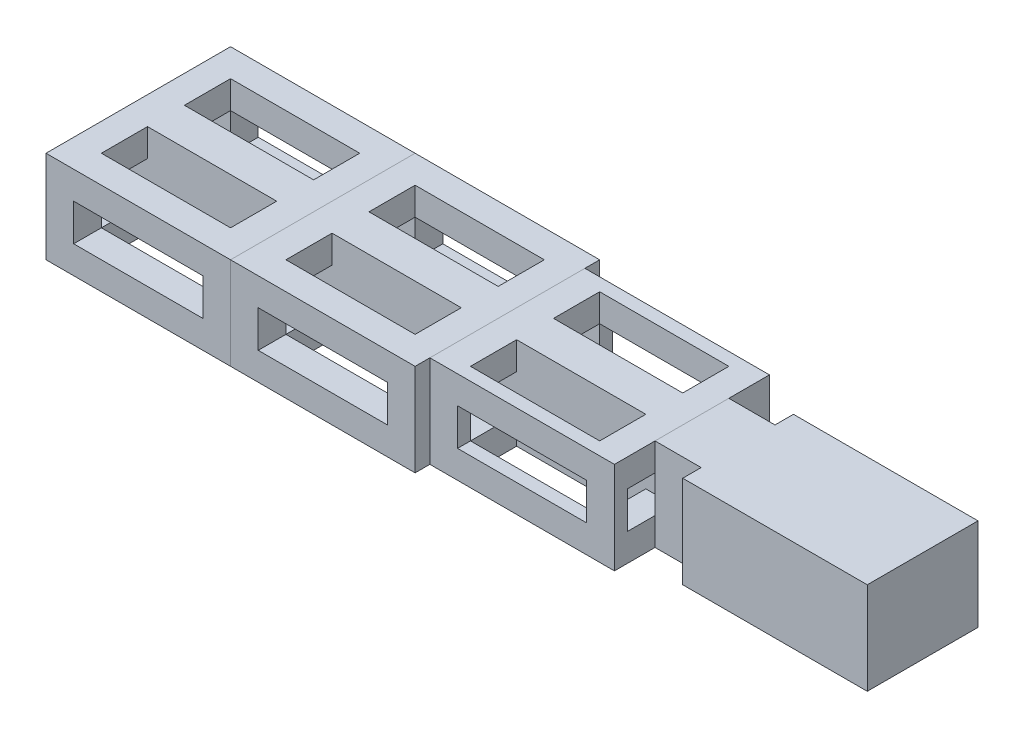
from build123d import *

# Parameters (mm, degrees)
SKETCH_1_W           = 20
SKETCH_1_H           = 20
EXTRUDE_1_DEPTH      = 10
SKETCH_1_3_W         = 20
SKETCH_1_3_H         = 20
EXTRUDE_2_DEPTH      = 10
SKETCH_1_4_W         = 20
SKETCH_1_4_H         = 20
EXTRUDE_3_DEPTH      = 10
SKETCH_2_W           = 14
SKETCH_2_H           = 4
CUT_EXTRUDE_1_DEPTH  = 61
SKETCH_3_W           = 14
SKETCH_3_H           = 4
CUT_EXTRUDE_2_DEPTH  = 21
SKETCH_4_W           = 14
SKETCH_4_H           = 14
CUT_EXTRUDE_3_DEPTH  = 11
SKETCH_5_W           = 20
SKETCH_5_H           = 10
EXTRUDE_4_DEPTH      = 10
EXTRUDE_4_DEPTH_BACK = 10
SKETCH_6_W           = 8
SKETCH_6_H           = 10
EXTRUDE_5_DEPTH      = 5
SKETCH_7_W           = 20
SKETCH_7_H           = 10
CUT_EXTRUDE_4_DEPTH  = 1.6
CUT_EXTRUDE_START    = -20
SKETCH_7_2_W         = 20
SKETCH_7_2_H         = 10
CUT_EXTRUDE_5_DEPTH  = 1.6
SKETCH_8_W           = 20
SKETCH_8_H           = 10
CUT_EXTRUDE_6_DEPTH  = 4
SKETCH_8_2_W         = 20
SKETCH_8_2_H         = 10
CUT_EXTRUDE_9_DEPTH  = 4
SKETCH_9_W           = 4
SKETCH_9_H           = 10
EXTRUDE_6_DEPTH      = 20
SKETCH_10_W          = 4
SKETCH_10_H          = 10
EXTRUDE_7_DEPTH      = 20
SKETCH_11_W          = 4
SKETCH_11_H          = 10
EXTRUDE_8_DEPTH      = 20


with BuildPart() as part:
    # Sketch 1 → Extrude 1 (new body)
    with BuildSketch(Plane(origin=(0, 0, 0), x_dir=(1, 0, 0), z_dir=(0, 1, 0))):
        with Locations((-20, 0)):
            Rectangle(SKETCH_1_W, SKETCH_1_H)
    extrude(amount=EXTRUDE_1_DEPTH)


with BuildPart() as body_2:
    # Sketch 1_3 → Extrude 2 (new body)
    with BuildSketch(Plane(origin=(0, 0, 0), x_dir=(1, 0, 0), z_dir=(0, 1, 0))):
        Rectangle(SKETCH_1_3_W, SKETCH_1_3_H)
    extrude(amount=EXTRUDE_2_DEPTH)


with BuildPart() as body_3:
    # Sketch 1_4 → Extrude 3 (new body)
    with BuildSketch(Plane(origin=(0, 0, 0), x_dir=(1, 0, 0), z_dir=(0, 1, 0))):
        with Locations((20, 0)):
            Rectangle(SKETCH_1_4_W, SKETCH_1_4_H)
    extrude(amount=EXTRUDE_3_DEPTH)


with BuildPart() as cut_extrude_1_tool:
    # Sketch 2 → Cut-Extrude 1 (new body, through all)
    with BuildSketch(Plane.ZY.offset(30)):
        with Locations((0, 5)):
            Rectangle(SKETCH_2_W, SKETCH_2_H)
    extrude(amount=-CUT_EXTRUDE_1_DEPTH)


with BuildPart() as part_1:
    add(part.part)

    # Cut-Extrude 1: cut by cut_extrude_1_tool
    add(cut_extrude_1_tool.part, mode=Mode.SUBTRACT)


with BuildPart() as body_2_1:
    add(body_2.part)

    # Cut-Extrude 1: cut by cut_extrude_1_tool
    add(cut_extrude_1_tool.part, mode=Mode.SUBTRACT)


with BuildPart() as body_3_1:
    add(body_3.part)

    # Cut-Extrude 1: cut by cut_extrude_1_tool
    add(cut_extrude_1_tool.part, mode=Mode.SUBTRACT)


with BuildPart() as cut_extrude_2_tool:
    # Sketch 3 → Cut-Extrude 2 (new body, through all)
    with BuildSketch(Plane(origin=(0, 0, -10), x_dir=(-1, 0, 0), z_dir=(0, 0, -1))):
        with Locations((-20, 5)):
            Rectangle(SKETCH_3_W, SKETCH_3_H)
        with Locations((0, 5)):
            Rectangle(SKETCH_3_W, SKETCH_3_H)
        with Locations((20, 5)):
            Rectangle(SKETCH_3_W, SKETCH_3_H)
    extrude(amount=-CUT_EXTRUDE_2_DEPTH)


with BuildPart() as part_2:
    add(part_1.part)

    # Cut-Extrude 2: cut by cut_extrude_2_tool
    add(cut_extrude_2_tool.part, mode=Mode.SUBTRACT)


with BuildPart() as body_2_2:
    add(body_2_1.part)

    # Cut-Extrude 2: cut by cut_extrude_2_tool
    add(cut_extrude_2_tool.part, mode=Mode.SUBTRACT)


with BuildPart() as body_3_2:
    add(body_3_1.part)

    # Cut-Extrude 2: cut by cut_extrude_2_tool
    add(cut_extrude_2_tool.part, mode=Mode.SUBTRACT)


with BuildPart() as cut_extrude_3_tool:
    # Sketch 4 → Cut-Extrude 3 (new body, through all)
    with BuildSketch(Plane(origin=(0, 10, 0), x_dir=(1, 0, 0), z_dir=(0, 1, 0))):
        with Locations((-20, 0)):
            Rectangle(SKETCH_4_W, SKETCH_4_H)
        Rectangle(SKETCH_4_W, SKETCH_4_H)
        with Locations((20, 0)):
            Rectangle(SKETCH_4_W, SKETCH_4_H)
    extrude(amount=-CUT_EXTRUDE_3_DEPTH)


with BuildPart() as part_3:
    add(part_2.part)

    # Cut-Extrude 3: cut by cut_extrude_3_tool
    add(cut_extrude_3_tool.part, mode=Mode.SUBTRACT)

    # Sketch 11 → Extrude 8 (add)
    with BuildSketch(Plane.ZY.offset(30)):
        with Locations((0, 5)):
            Rectangle(SKETCH_11_W, SKETCH_11_H)
    extrude(amount=-EXTRUDE_8_DEPTH)


with BuildPart() as body_2_3:
    add(body_2_2.part)

    # Cut-Extrude 3: cut by cut_extrude_3_tool
    add(cut_extrude_3_tool.part, mode=Mode.SUBTRACT)

    # Sketch 10 → Extrude 7 (add)
    with BuildSketch(Plane(origin=(10, 0, 0), x_dir=(0, 0, -1), z_dir=(1, 0, 0))):
        with Locations((0, 5)):
            Rectangle(SKETCH_10_W, SKETCH_10_H)
    extrude(amount=-EXTRUDE_7_DEPTH)


with BuildPart() as body_3_3:
    add(body_3_2.part)

    # Cut-Extrude 3: cut by cut_extrude_3_tool
    add(cut_extrude_3_tool.part, mode=Mode.SUBTRACT)

    # Sketch 7 → Cut-Extrude 4 (cut)
    with BuildSketch(Plane(origin=(0, 0, -10), x_dir=(-1, 0, 0), z_dir=(0, 0, -1))):
        with Locations((-20, 5)):
            Rectangle(SKETCH_7_W, SKETCH_7_H)
    extrude(amount=-CUT_EXTRUDE_4_DEPTH, mode=Mode.SUBTRACT)

    # Sketch 7_2 → Cut-Extrude 5 (cut)
    with BuildSketch(Plane(origin=(0, 0, -10), x_dir=(-1, 0, 0), z_dir=(0, 0, -1)).offset(CUT_EXTRUDE_START)):
        with Locations((-20, 5)):
            Rectangle(SKETCH_7_2_W, SKETCH_7_2_H)
    extrude(amount=CUT_EXTRUDE_5_DEPTH, mode=Mode.SUBTRACT)

    # Sketch 9 → Extrude 6 (add)
    with BuildSketch(Plane.ZY.offset(-30)):
        with Locations((0, 5)):
            Rectangle(SKETCH_9_W, SKETCH_9_H)
    extrude(amount=EXTRUDE_6_DEPTH)


with BuildPart() as body_4:
    # Sketch 5 → Extrude 4 (new body, two sides)
    with BuildSketch(Plane.XY) as extrude_4_sk:
        with Locations((45, 5)):
            Rectangle(SKETCH_5_W, SKETCH_5_H)
    extrude(amount=EXTRUDE_4_DEPTH)
    extrude(extrude_4_sk.sketch, amount=-EXTRUDE_4_DEPTH_BACK)

    # Sketch 6 → Extrude 5 (add)
    with BuildSketch(Plane.ZY.offset(-35)):
        with Locations((0, 5)):
            Rectangle(SKETCH_6_W, SKETCH_6_H)
    extrude(amount=EXTRUDE_5_DEPTH)

    # Sketch 8 → Cut-Extrude 6 (cut)
    with BuildSketch(Plane(origin=(0, 0, -10), x_dir=(-1, 0, 0), z_dir=(0, 0, -1))):
        with Locations((-45, 5)):
            Rectangle(SKETCH_8_W, SKETCH_8_H)
    extrude(amount=-CUT_EXTRUDE_6_DEPTH, mode=Mode.SUBTRACT)

    # Sketch 8_2 → Cut-Extrude 9 (cut)
    with BuildSketch(Plane(origin=(0, 0, -10), x_dir=(-1, 0, 0), z_dir=(0, 0, -1)).offset(CUT_EXTRUDE_START)):
        with Locations((-45, 5)):
            Rectangle(SKETCH_8_2_W, SKETCH_8_2_H)
    extrude(amount=CUT_EXTRUDE_9_DEPTH, mode=Mode.SUBTRACT)


solid = Compound([part_3.part, body_2_3.part, body_3_3.part, body_4.part])
